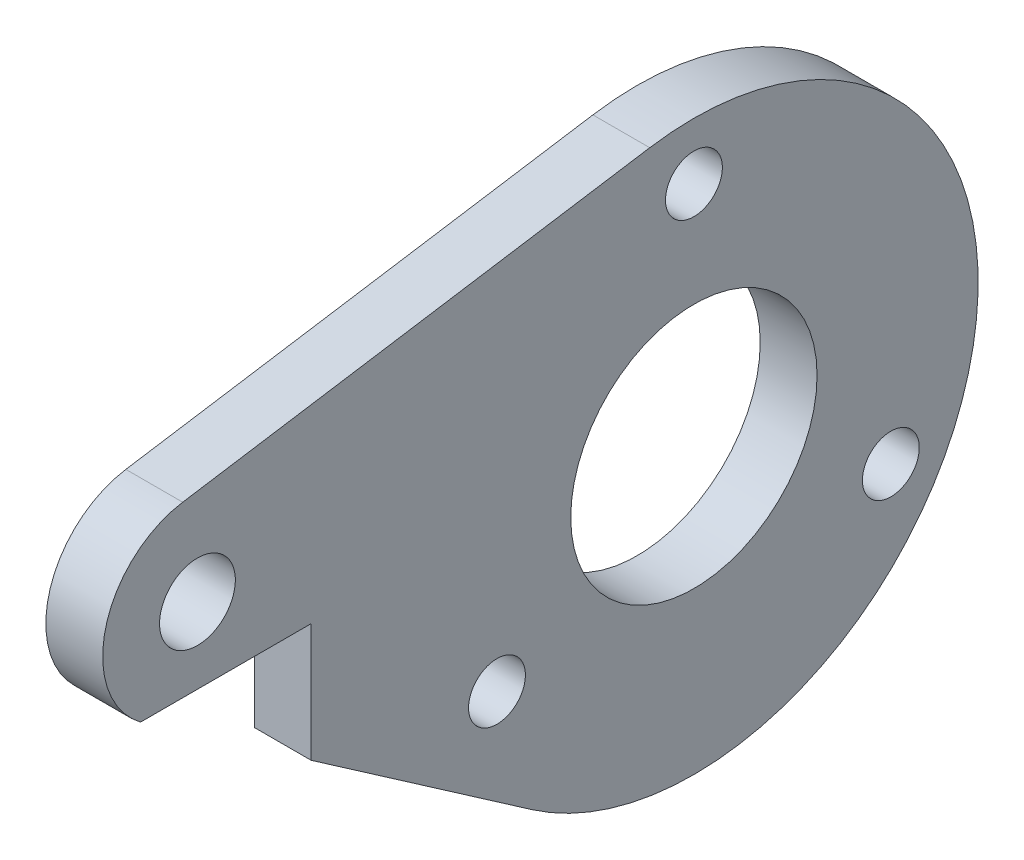
from build123d import *

# Parameters (mm, degrees)
ESQUISSE1_R             = 6.5
ESQUISSE1_R_2           = 1.5
ESQUISSE1_R_3           = 2
BOSS_EXTRU_1_DEPTH      = 3
ENL_V_MAT_EXTRU_1_DEPTH = 4


with BuildPart() as part:
    # Esquisse1 → Boss.-Extru.1 (new body)
    with BuildSketch(Plane.ZY):
        with BuildLine():
            Line((29.049319561, 1.891304582), (8.547958684, -12.326086254))
            ThreePointArc((8.547958684, -12.326086254), (-14.621490903, -3.348433031), (2.331837562, 14.817642646))
            Line((2.331837562, 14.817642646), (26.977279187, 10.939214215))
            ThreePointArc((26.977279187, 10.939214215), (31.073830301, 7.116144344), (29.049319561, 1.891304582))
        make_face()
        Circle(ESQUISSE1_R, mode=Mode.SUBTRACT)
        with Locations((-10.392304845, -6)):
            Circle(ESQUISSE1_R_2, mode=Mode.SUBTRACT)
        with Locations((0, 12)):
            Circle(ESQUISSE1_R_2, mode=Mode.SUBTRACT)
        with Locations((10.392304845, -6)):
            Circle(ESQUISSE1_R_2, mode=Mode.SUBTRACT)
        with Locations((26.2, 6)):
            Circle(ESQUISSE1_R_3, mode=Mode.SUBTRACT)
    extrude(amount=-BOSS_EXTRU_1_DEPTH)

    # Esquisse2 → Enlèv. mat.-Extru.1 (cut, through all)
    with BuildSketch(Plane(origin=(3, 0, 0), x_dir=(0, 0, -1), z_dir=(1, 0, 0))):
        Polygon((-29.206057462, 2), (-20.2, 2), (-20.2, -4.245567774), align=None)
    extrude(amount=-ENL_V_MAT_EXTRU_1_DEPTH, mode=Mode.SUBTRACT)


solid = part.part
